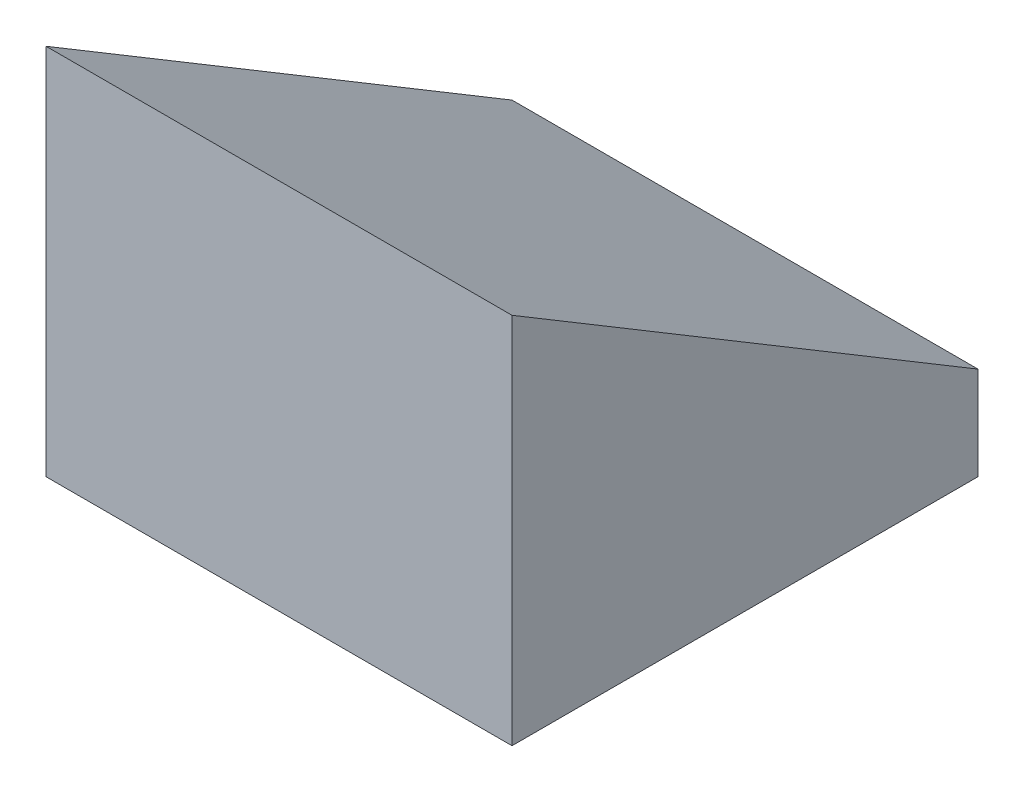
from build123d import *

# Parameters (mm, degrees)
BOSS_EXTRUDE1_DEPTH = 5
CUT_EXTRUDE1_DEPTH  = 4
BOSS_EXTRUDE2_DEPTH = 1


with BuildPart() as part:
    # Sketch3 → Boss-Extrude1 (new body)
    with BuildSketch(Plane(origin=(0, 0, 0), x_dir=(0, 0, -1), z_dir=(1, 0, 0))):
        Polygon((5, 0), (5, 1), (0, 4), (0, 0), align=None)
    extrude(amount=BOSS_EXTRUDE1_DEPTH)

    # Sketch3_3 → Cut-Extrude1 (cut)
    with BuildSketch(Plane(origin=(0, 0, 0), x_dir=(0, 0, -1), z_dir=(1, 0, 0))):
        Polygon((1, 0), (4, 0), (4, 1), (1, 2.8), align=None)
    extrude(amount=CUT_EXTRUDE1_DEPTH, mode=Mode.SUBTRACT)

    # Sketch3_4 → Boss-Extrude2 (add)
    with BuildSketch(Plane(origin=(0, 0, 0), x_dir=(0, 0, -1), z_dir=(1, 0, 0))):
        Polygon((1, 0), (4, 0), (4, 1), (1, 2.8), align=None)
    extrude(amount=BOSS_EXTRUDE2_DEPTH)


solid = part.part
